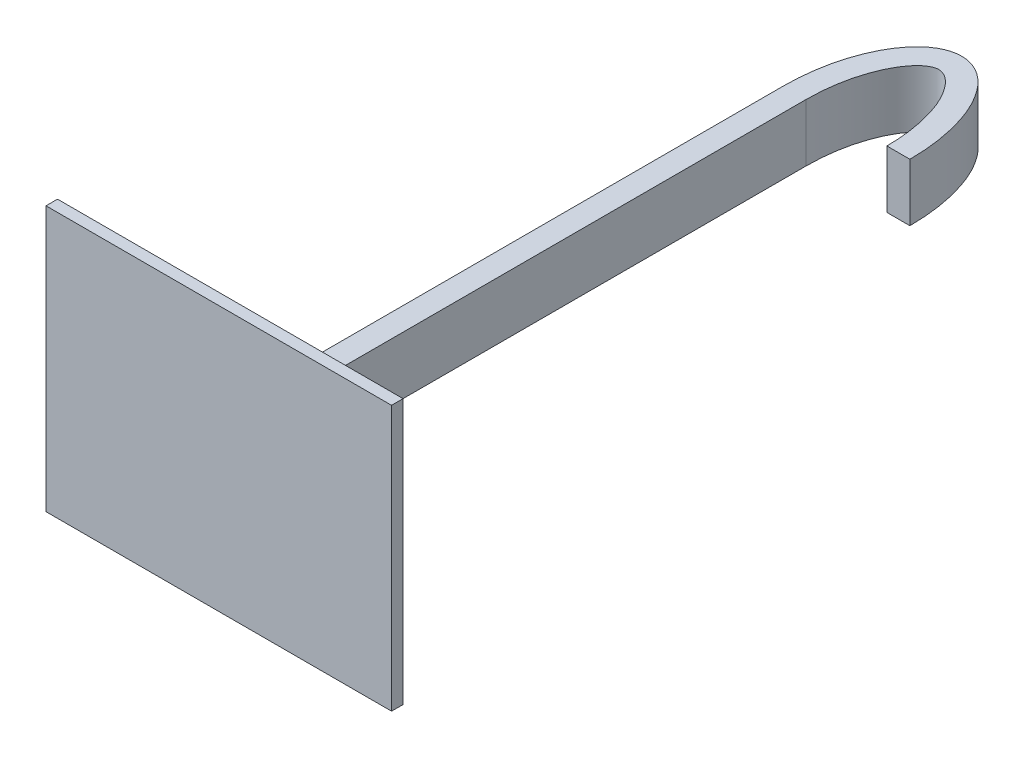
from build123d import *

# Parameters (mm, degrees)
SKETCH_1_W      = 30
SKETCH_1_H      = 23
EXTRUDE_1_DEPTH = 1
SKETCH_2_W      = 2
SKETCH_2_H      = 5
EXTRUDE_2_DEPTH = 50
EXTRUDE_3_DEPTH = 5


with BuildPart() as part:
    # 草图1 → 凸台-拉伸1 (new body)
    with BuildSketch(Plane.XY):
        Rectangle(SKETCH_1_W, SKETCH_1_H)
    extrude(amount=EXTRUDE_1_DEPTH)

    # 草图2 → 凸台-拉伸2 (add)
    with BuildSketch(Plane.XY.offset(1)):
        Rectangle(SKETCH_2_W, SKETCH_2_H)
    extrude(amount=-EXTRUDE_2_DEPTH)

    # 草图3 → 凸台-拉伸3 (add)
    with BuildSketch(Plane.XZ.offset(2.5)):
        with BuildLine():
            Line((10, -49), (8, -49))
            add(Edge.make_bspline(
                [(1, -49), (1, -49.619868087), (1.073075658, -50.875846969), (1.496894212, -53.232853061), (2.298455082, -55.177429757), (3.225136579, -56.36639736), (3.863278976, -56.854176817), (4.333703996, -57.010353831), (4.696944934, -57.005945727), (5.181727934, -56.829303178), (6.046876052, -56.139577454), (7.226468744, -54.246764202), (7.865607285, -51.549457002), (7.991098661, -49.744152661), (8, -49.168487373), (8, -49)],
                knots=[-1.570796327, -1.570796327, -1.570796327, -1.570796327, -1.360248412, -1.149700497, -0.728604667, -0.518056752, -0.307508837, -0.096960922, 0.113586993, 0.324134908, 0.534682823, 0.955778653, 1.376874483, 1.51400283, 1.570796327, 1.570796327, 1.570796327, 1.570796327], degree=3))
            Line((1, -49), (-1, -49))
            add(Edge.make_bspline(
                [(-1, -49), (-1, -59), (4.5, -59), (10, -59), (10, -49)],
                knots=[1.570796327, 1.570796327, 1.570796327, 3.141592654, 3.141592654, 4.71238898, 4.71238898, 4.71238898], degree=2, weights=[1, 0.707106781, 1, 0.707106781, 1]))
        make_face()
    extrude(amount=-EXTRUDE_3_DEPTH)


solid = part.part
